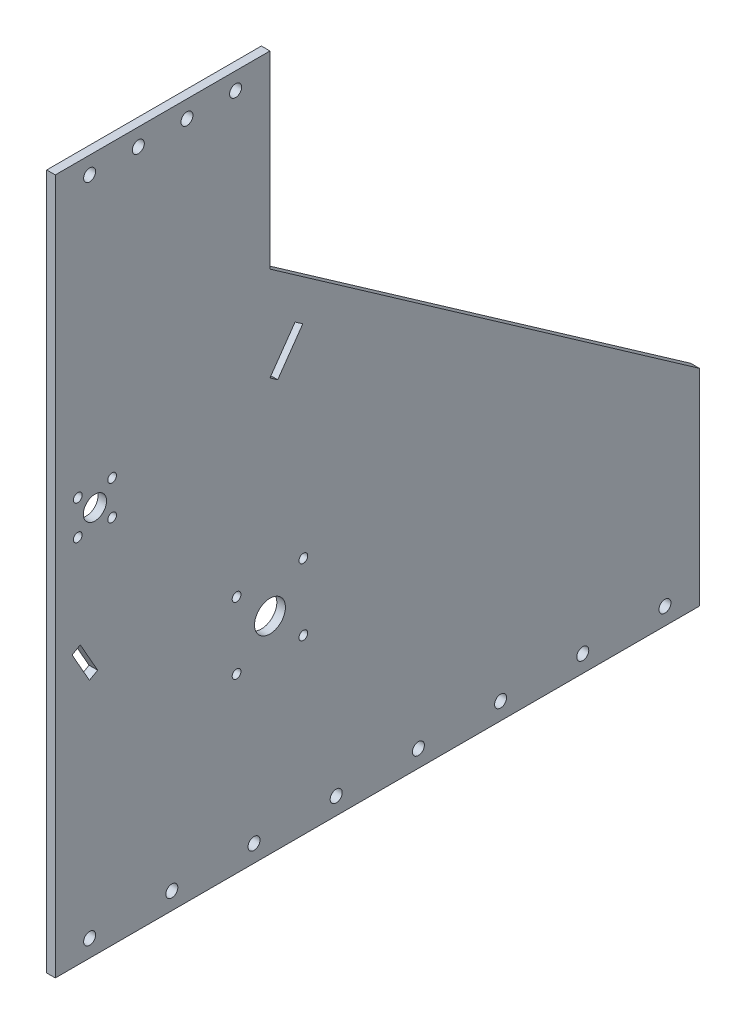
from build123d import *

# Parameters (mm, degrees)
IZIM1_R                     = 13.5
IZIM1_R_2                   = 5.1
IZIM1_R_3                   = 18
IZIM1_R_4                   = 7
Y_KSEKLIK_EKSTR_ZYON1_DEPTH = 10


with BuildPart() as part:
    # Çizim1 → Yükseklik-Ekstrüzyon1 (new body)
    with BuildSketch(Plane(origin=(0, 0, 0), x_dir=(0, 0, -1), z_dir=(1, 0, 0))):
        Polygon((-250, 350), (-250, 570), (0, 570), (0, 350), (500, 0), (500, -200), (500, -240), (-250, -240), (-250, -200), align=None)
        with Locations((-203.812062632, 211.374016696)):
            Circle(IZIM1_R, mode=Mode.SUBTRACT)
        with Locations((-183.812062632, 231.374016696)):
            Circle(IZIM1_R_2, mode=Mode.SUBTRACT)
        with Locations((-223.812062632, 231.374016696)):
            Circle(IZIM1_R_2, mode=Mode.SUBTRACT)
        with Locations((-183.812062632, 191.374016696)):
            Circle(IZIM1_R_2, mode=Mode.SUBTRACT)
        with Locations((-223.812062632, 191.374016696)):
            Circle(IZIM1_R_2, mode=Mode.SUBTRACT)
        Circle(IZIM1_R_3, mode=Mode.SUBTRACT)
        with Locations((-38.890872965, 38.890872965)):
            Circle(IZIM1_R_2, mode=Mode.SUBTRACT)
        with Locations((38.890872965, 38.890872965)):
            Circle(IZIM1_R_2, mode=Mode.SUBTRACT)
        with Locations((38.890872965, -38.890872965)):
            Circle(IZIM1_R_2, mode=Mode.SUBTRACT)
        with Locations((-38.890872965, -38.890872965)):
            Circle(IZIM1_R_2, mode=Mode.SUBTRACT)
        with Locations((-210, 550)):
            Circle(IZIM1_R_4, mode=Mode.SUBTRACT)
        with Locations((-153.333333333, 550)):
            Circle(IZIM1_R_4, mode=Mode.SUBTRACT)
        with Locations((-96.666666667, 550)):
            Circle(IZIM1_R_4, mode=Mode.SUBTRACT)
        with Locations((-40, 550)):
            Circle(IZIM1_R_4, mode=Mode.SUBTRACT)
        with Locations((-210, -220)):
            Circle(IZIM1_R_4, mode=Mode.SUBTRACT)
        with Locations((-114.285714286, -220)):
            Circle(IZIM1_R_4, mode=Mode.SUBTRACT)
        with Locations((-18.571428571, -220)):
            Circle(IZIM1_R_4, mode=Mode.SUBTRACT)
        with Locations((77.142857143, -220)):
            Circle(IZIM1_R_4, mode=Mode.SUBTRACT)
        with Locations((172.857142857, -220)):
            Circle(IZIM1_R_4, mode=Mode.SUBTRACT)
        with Locations((268.571428571, -220)):
            Circle(IZIM1_R_4, mode=Mode.SUBTRACT)
        with Locations((364.285714286, -220)):
            Circle(IZIM1_R_4, mode=Mode.SUBTRACT)
        with Locations((460, -220)):
            Circle(IZIM1_R_4, mode=Mode.SUBTRACT)
        Polygon((29.246579563, 281.988117893), (0, 240.207289947), (9.011551126, 233.899204159), (38.258130688, 275.680032105), align=None, mode=Mode.SUBTRACT)
        Polygon((-200.681608906, 45.789510008), (-220.902149255, 81.456437938), (-230.471325041, 76.031414918), (-210.250784693, 40.364486987), align=None, mode=Mode.SUBTRACT)
    extrude(amount=Y_KSEKLIK_EKSTR_ZYON1_DEPTH)


solid = part.part
